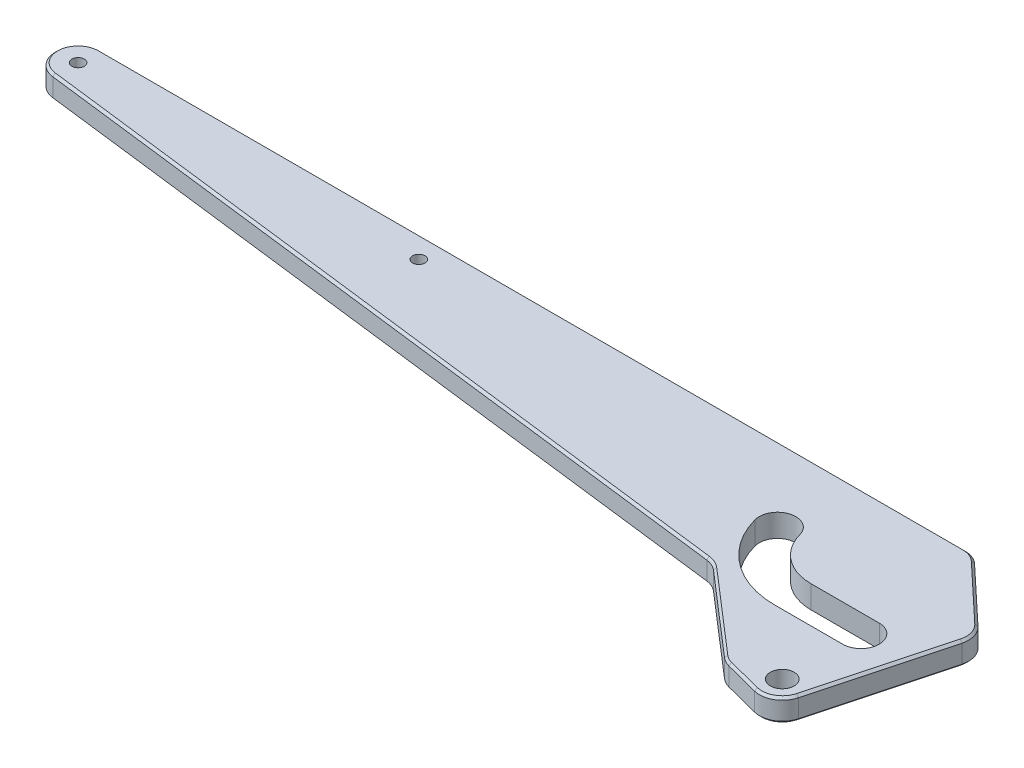
from build123d import *

# Parameters (mm, degrees)
BOSS_EXTRUDE1_DEPTH              = 5
SLOT_DEPTH                       = 11
F_10_5_10_5_DIAMETER_HOLE1_D     = 10.5
F_10_5_10_5_DIAMETER_HOLE1_DEPTH = 15
F_10_5_10_5_DIAMETER_HOLE1_TIP   = 3.15451825
CBORE_FOR_M5_SHCS2_D             = 5.5
CBORE_FOR_M5_SHCS2_DEPTH         = 21.6
CBORE_FOR_M5_SHCS2_CBORE_D       = 10
CBORE_FOR_M5_SHCS2_CBORE_DEPTH   = 5
CBORE_FOR_M5_SHCS2_TIP           = 1.652366702
CUT_EXTRUDE3_DEPTH               = 11
FILLET1_R                        = 10
CHAMFER1_SIZE                    = 1


with BuildPart() as part:
    # Sketch1 → Boss-Extrude1 (new body, symmetric)
    with BuildSketch(Plane(origin=(0, 0, 0), x_dir=(1, 0, 0), z_dir=(0, 1, 0))):
        with BuildLine():
            Line((-390, 90), (34.468189123, 90))
            Line((34.468189123, 90), (9.659258263, -2.588190451))
            ThreePointArc((9.659258263, -2.588190451), (5.03987296, -8.63711066), (-2.499017827, -9.682711908))
            Line((-2.499017827, -9.682711908), (-20, -5.16587129))
            Line((-20, -5.16587129), (-60, 29.405996647))
            Line((-60, 29.405996647), (-391.218693434, 70.074538484))
            ThreePointArc((-391.218693434, 70.074538484), (-399.981347984, 80.610485395), (-390, 90))
        make_face()
    extrude(amount=BOSS_EXTRUDE1_DEPTH, both=True)

    # Sketch4 → Slot (cut, through all)
    with BuildSketch(Plane(origin=(0, 5, 0), x_dir=(1, 0, 0), z_dir=(0, 1, 0))):
        with BuildLine():
            Line((-30, 26.591016), (0, 26.591016))
            ThreePointArc((0, 26.591016), (8.05, 34.641016), (0, 42.691016))
            Line((0, 42.691016), (-30, 42.691016))
            ThreePointArc((-30, 42.691016), (-43.362313367, 47.226910181), (-51.202071887, 58.95993796))
            ThreePointArc((-51.202071887, 58.95993796), (-61.061268102, 64.652147549), (-66.75347769, 54.792951334))
            ThreePointArc((-66.75347769, 54.792951334), (-53.163372374, 34.453921402), (-30, 26.591016))
        make_face()
    extrude(amount=-SLOT_DEPTH, mode=Mode.SUBTRACT)

    # Ø10.5 (10.5) Diameter Hole1
    with Locations(Plane(origin=(0, 5, 0), x_dir=(1, 0, 0), z_dir=(0, 1, 0))):
        with Locations((0, 0)):
            Hole(F_10_5_10_5_DIAMETER_HOLE1_D / 2, depth=F_10_5_10_5_DIAMETER_HOLE1_DEPTH)
            with Locations((0, 0, -(F_10_5_10_5_DIAMETER_HOLE1_DEPTH + F_10_5_10_5_DIAMETER_HOLE1_TIP / 2))):  # 118° drill point
                Cone(0, F_10_5_10_5_DIAMETER_HOLE1_D / 2, F_10_5_10_5_DIAMETER_HOLE1_TIP, mode=Mode.SUBTRACT)

    # CBORE for M5 SHCS2
    with Locations(Plane(origin=(0, -5, 0), x_dir=(-1, 0, 0), z_dir=(0, -1, 0))):
        with Locations((390, 80), (240, 80)):
            CounterBoreHole(CBORE_FOR_M5_SHCS2_D / 2, CBORE_FOR_M5_SHCS2_CBORE_D / 2, CBORE_FOR_M5_SHCS2_CBORE_DEPTH, depth=CBORE_FOR_M5_SHCS2_DEPTH)
            with Locations((0, 0, -(CBORE_FOR_M5_SHCS2_DEPTH + CBORE_FOR_M5_SHCS2_TIP / 2))):  # 118° drill point
                Cone(0, CBORE_FOR_M5_SHCS2_D / 2, CBORE_FOR_M5_SHCS2_TIP, mode=Mode.SUBTRACT)

    # Sketch13 → Cut-Extrude3 (cut, through all)
    with BuildSketch(Plane(origin=(0, 5, 0), x_dir=(1, 0, 0), z_dir=(0, 1, 0))):
        Polygon((-5.531810877, 90), (34.468189123, 90), (26.42971335, 60), align=None)
    extrude(amount=-CUT_EXTRUDE3_DEPTH, mode=Mode.SUBTRACT)

    # Fillet1
    fillet1_edges = [part.edges().sort_by_distance(p)[0] for p in [
        (-20, 0, 5.16587129),
        (-60, 0, -29.405996647),
        (26.42971335, 0, -60),
        (-5.531810877, 0, -90),
    ]]
    fillet(fillet1_edges, radius=FILLET1_R)

    # Chamfer1
    chamfer1_edges = [part.edges().sort_by_distance(p)[0] for p in [
        (-399.981347984, -5, -80.610485395),
        (5.03987296, 5, 8.63711066),
        (17.26978309, 5, -25.814674877),
        (-399.981347984, 5, -80.610485395),
        (9.709435896, 5, -75.694130232),
        (9.709435896, -5, -75.694130232),
        (-199.744878532, 5, -90),
        (-39.735397279, 5, -11.891367421),
        (17.26978309, -5, -25.814674877),
        (-10.11553696, 5, 7.716959206),
        (-19.874383451, 5, 4.92614185),
        (24.83814676, 5, -59.546431893),
        (-5.80958377, 5, -89.298189314),
        (-199.744878532, -5, -90),
        (-10.11553696, -5, 7.716959206),
        (5.03987296, -5, 8.63711066),
        (-39.735397279, -5, -11.891367421),
        (-19.874383451, -5, 4.92614185),
        (24.83814676, -5, -59.546431893),
        (-5.80958377, -5, -89.298189314),
        (-60.183408772, -5, -28.992469299),
        (-227.118878147, 5, -49.925614719),
        (-60.183408772, 5, -28.992469299),
        (-227.118878147, -5, -49.925614719),
    ]]
    chamfer(chamfer1_edges, length=CHAMFER1_SIZE)


solid = part.part
